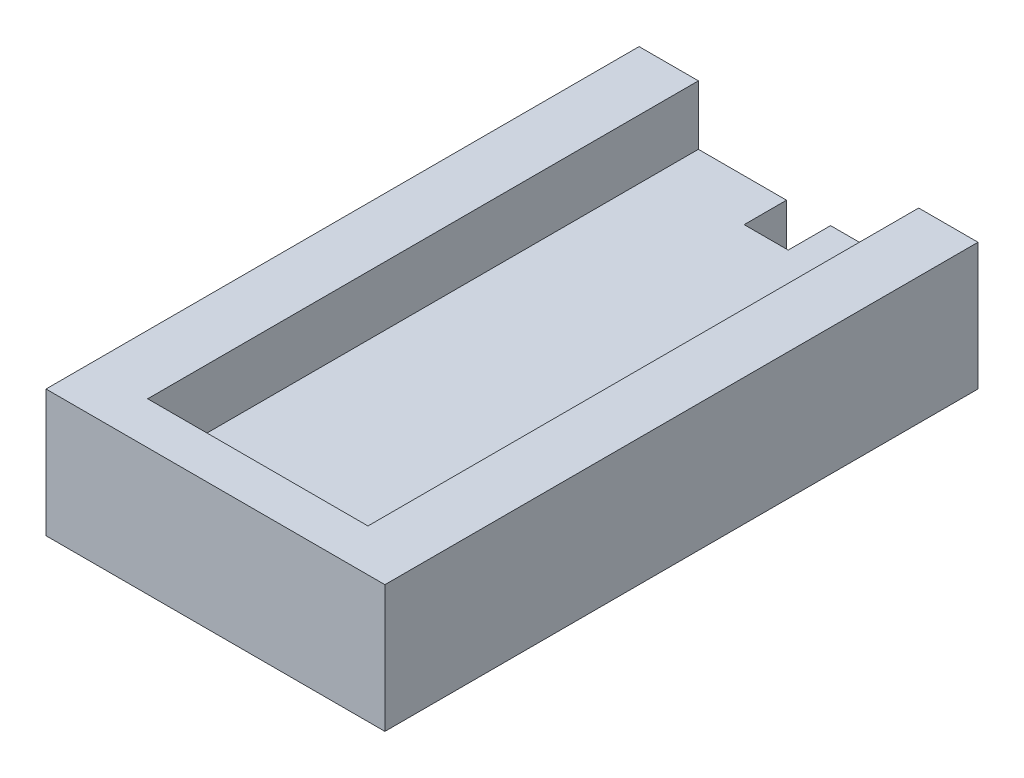
from build123d import *

# Parameters (mm, degrees)
SKETCH_1_W          = 40
SKETCH_1_H          = 30
EXTRUDE_1_DEPTH     = 70
SKETCH_2_W          = 26
SKETCH_2_H          = 14
CUT_EXTRUDE_1_DEPTH = 65
SKETCH_3_W          = 5.2
SKETCH_3_H          = 5
CUT_EXTRUDE_2_DEPTH = 10
SKETCH_4_W          = 5.2
SKETCH_4_H          = 5
CUT_EXTRUDE_3_DEPTH = 10


with BuildPart() as part:
    # ｽｹｯﾁ1 → ﾎﾞｽ - 押し出し1 (new body)
    with BuildSketch(Plane.XY):
        Rectangle(SKETCH_1_W, SKETCH_1_H)
    extrude(amount=EXTRUDE_1_DEPTH)

    # ｽｹｯﾁ2 → ｶｯﾄ - 押し出し1 (cut)
    with BuildSketch(Plane(origin=(0, 0, 0), x_dir=(-1, 0, 0), z_dir=(0, 0, -1))):
        Rectangle(SKETCH_2_W, SKETCH_2_H)
    extrude(amount=-CUT_EXTRUDE_1_DEPTH, mode=Mode.SUBTRACT)

    # ｽｹｯﾁ3 → ｶｯﾄ - 押し出し2 (cut)
    with BuildSketch(Plane(origin=(0, 7, 0), x_dir=(-1, 0, 0), z_dir=(0, -1, 0))):
        with Locations((0, -2.5)):
            Rectangle(SKETCH_3_W, SKETCH_3_H)
    extrude(amount=-CUT_EXTRUDE_2_DEPTH, mode=Mode.SUBTRACT)

    # ｽｹｯﾁ4 → ｶｯﾄ - 押し出し3 (cut)
    with BuildSketch(Plane(origin=(0, -7, 0), x_dir=(1, 0, 0), z_dir=(0, 1, 0))):
        with Locations((0, -2.5)):
            Rectangle(SKETCH_4_W, SKETCH_4_H)
    extrude(amount=-CUT_EXTRUDE_3_DEPTH, mode=Mode.SUBTRACT)

    # Surface Cut 1
    split(bisect_by=Plane(origin=(0, 0, 0), x_dir=(-1, 0, 0), z_dir=(0, -1, 0)), keep=Keep.TOP)


solid = part.part
